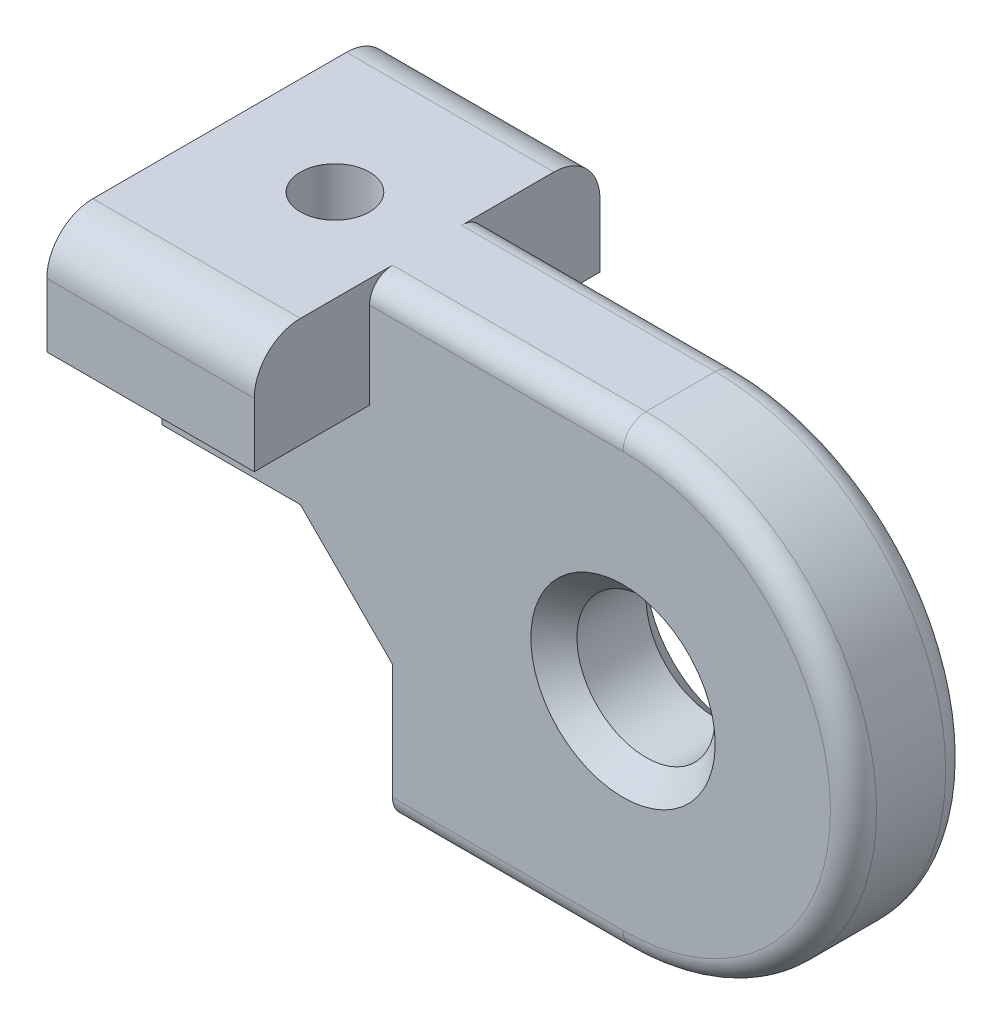
from build123d import *

# Parameters (mm, degrees)
SKETCH1_R           = 3
BOSS_EXTRUDE1_DEPTH = 2.5
SKETCH2_W           = 9
SKETCH2_H           = 4.761904762
BOSS_EXTRUDE2_DEPTH = 7.5
FILLET1_R           = 2
CHAMFER1_SIZE       = 1
FILLET2_R           = 1
SKETCH3_R           = 1.5
CUT_EXTRUDE1_DEPTH  = 20


with BuildPart() as part:
    # Sketch1 → Boss-Extrude1 (new body, symmetric)
    with BuildSketch(Plane.XY):
        with BuildLine():
            Line((0, 10), (-20, 10))
            Line((-20, 10), (-20, 0))
            Line((-20, 0), (-14, 0))
            Line((-14, 0), (-10, -4))
            Line((-10, -4), (-10, -10))
            Line((-10, -10), (0, -10))
            ThreePointArc((0, -10), (10, 0), (0, 10))
        make_face()
        Circle(SKETCH1_R, mode=Mode.SUBTRACT)
    extrude(amount=BOSS_EXTRUDE1_DEPTH, both=True)

    # Sketch2 → Boss-Extrude2 (add, symmetric)
    with BuildSketch(Plane.XY):
        with Locations((-15.5, 7.619047619)):
            Rectangle(SKETCH2_W, SKETCH2_H)
    extrude(amount=BOSS_EXTRUDE2_DEPTH, both=True)

    # Fillet1
    fillet1_edges = [part.edges().sort_by_distance(p)[0] for p in [
        (-15.5, 10, -7.5),
        (-15.5, 10, 7.5),
    ]]
    fillet(fillet1_edges, radius=FILLET1_R)

    # Chamfer1
    chamfer1_edges = [part.edges().sort_by_distance(p)[0] for p in [
        (-3, 0, -2.5),
        (-3, 0, 2.5),
    ]]
    chamfer(chamfer1_edges, length=CHAMFER1_SIZE)

    # Fillet2
    fillet2_edges = [part.edges().sort_by_distance(p)[0] for p in [
        (-5, -10, 2.5),
        (10, 0, 2.5),
        (-5.5, 10, 2.5),
        (-5.5, 10, -2.5),
        (10, 0, -2.5),
        (-5, -10, -2.5),
    ]]
    fillet(fillet2_edges, radius=FILLET2_R)

    # Sketch3 → Cut-Extrude1 (cut)
    with BuildSketch(Plane(origin=(0, 10, 0), x_dir=(1, 0, 0), z_dir=(0, 1, 0))):
        with Locations((-15, 0)):
            Circle(SKETCH3_R)
    extrude(amount=-CUT_EXTRUDE1_DEPTH, mode=Mode.SUBTRACT)


solid = part.part
